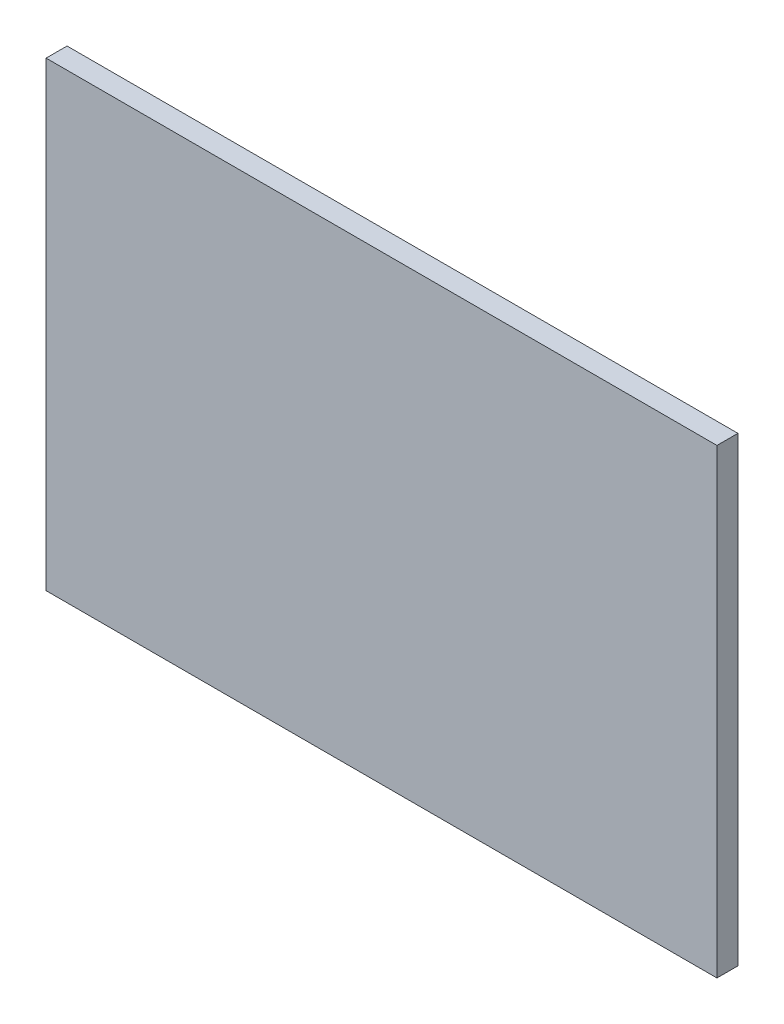
from build123d import *

# Parameters (mm, degrees)
SKETCH1_W           = 800
SKETCH1_H           = 550
BOSS_EXTRUDE1_DEPTH = 25


with BuildPart() as part:
    # Sketch1 → Boss-Extrude1 (new body)
    with BuildSketch(Plane.XY):
        with Locations((400, 275)):
            Rectangle(SKETCH1_W, SKETCH1_H)
    extrude(amount=BOSS_EXTRUDE1_DEPTH)


solid = part.part
